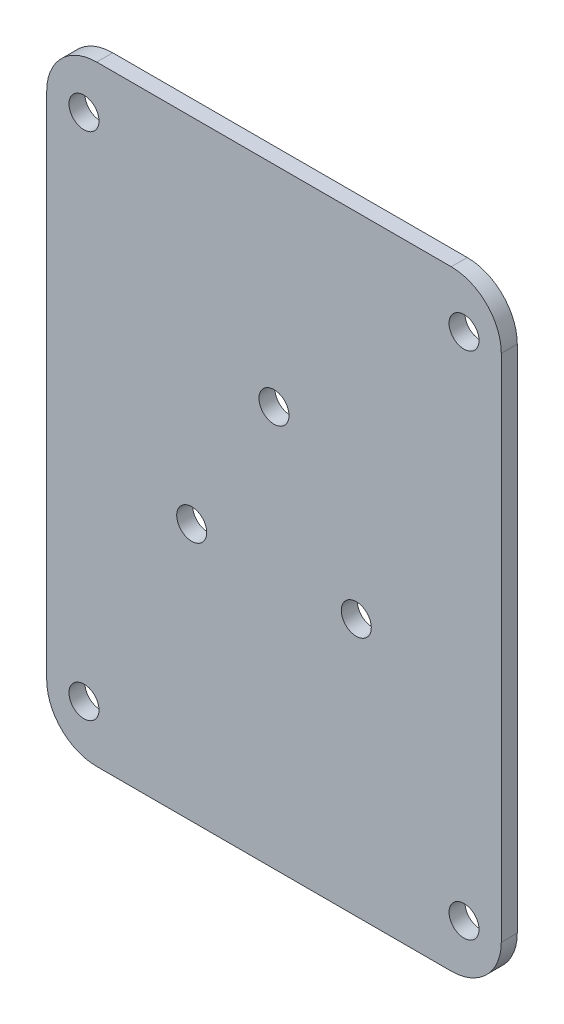
from build123d import *

# Parameters (mm, degrees)
SKETCH_1_W      = 45.450980392
SKETCH_1_H      = 61
SKETCH_1_R      = 1.5
EXTRUDE_1_DEPTH = 1.6
FILLET_1_R      = 5


with BuildPart() as part:
    # 草图1 → 凸台-拉伸1 (new body)
    with BuildSketch(Plane.XY):
        Rectangle(SKETCH_1_W, SKETCH_1_H)
        with Locations((19, -25.5)):
            Circle(SKETCH_1_R, mode=Mode.SUBTRACT)
        with Locations((-19, -25.5)):
            Circle(SKETCH_1_R, mode=Mode.SUBTRACT)
        with Locations((-19, 25.5)):
            Circle(SKETCH_1_R, mode=Mode.SUBTRACT)
        with Locations((19, 25.5)):
            Circle(SKETCH_1_R, mode=Mode.SUBTRACT)
        with Locations((-8.227241336, -4.75)):
            Circle(SKETCH_1_R, mode=Mode.SUBTRACT)
        with Locations((8.227241336, -4.75)):
            Circle(SKETCH_1_R, mode=Mode.SUBTRACT)
        with Locations((0, 9.5)):
            Circle(SKETCH_1_R, mode=Mode.SUBTRACT)
    extrude(amount=EXTRUDE_1_DEPTH)

    # 圆角1
    fillet_1_edges = [part.edges().sort_by_distance(p)[0] for p in [
        (22.725490196, -30.5, 0.8),
        (-22.725490196, -30.5, 0.8),
        (-22.725490196, 30.5, 0.8),
        (22.725490196, 30.5, 0.8),
    ]]
    fillet(fillet_1_edges, radius=FILLET_1_R)


solid = part.part
